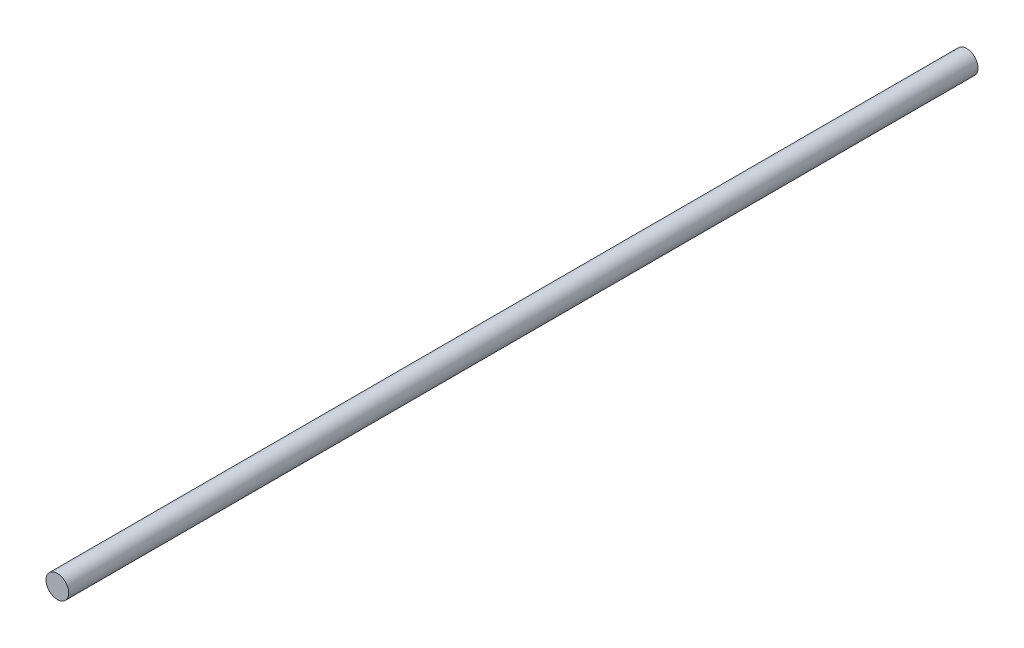
from build123d import *

# Parameters (mm, degrees)
CROQUIS1_R              = 2.5
SALIENTE_EXTRUIR1_DEPTH = 100


with BuildPart() as part:
    # Croquis1 → Saliente-Extruir1 (new body, symmetric)
    with BuildSketch(Plane.XY):
        Circle(CROQUIS1_R)
    extrude(amount=SALIENTE_EXTRUIR1_DEPTH, both=True)


solid = part.part
